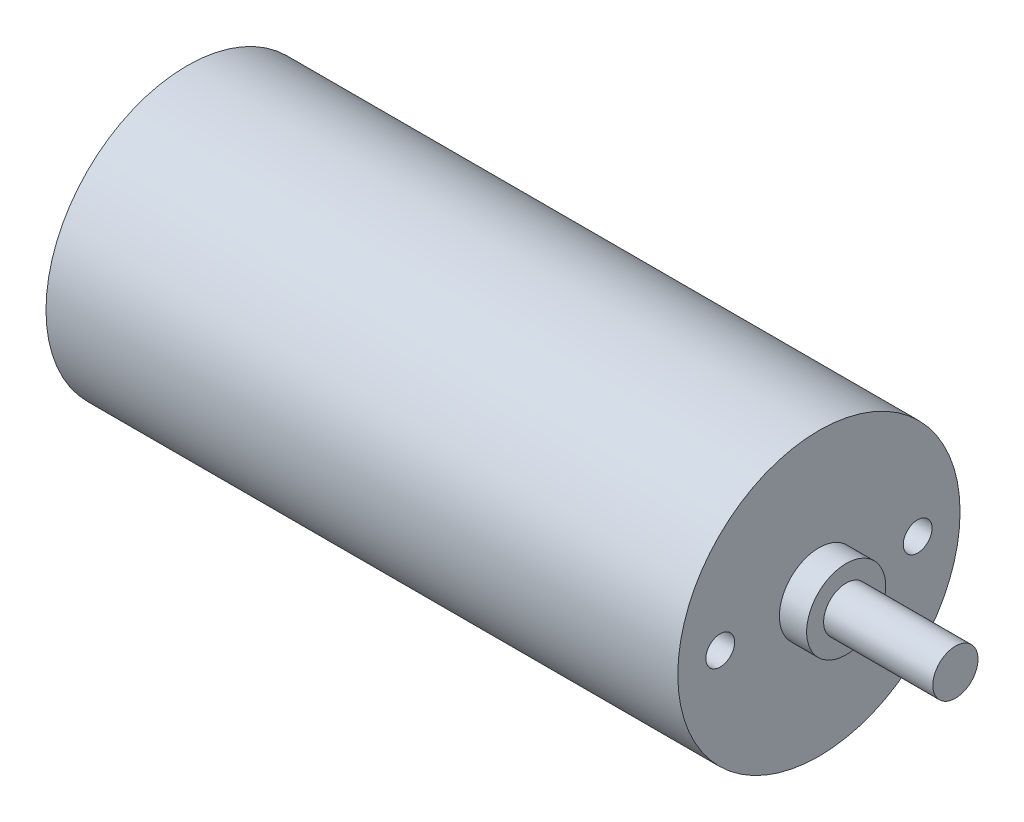
from build123d import *

# Parameters (mm, degrees)
SKETCH1_R           = 1.99
BOSS_EXTRUDE1_DEPTH = 12.03
SKETCH1_3_R         = 3.485
SKETCH1_3_R_2       = 1.99
BOSS_EXTRUDE2_DEPTH = 2.4
SKETCH1_4_R         = 12.44
SKETCH1_4_R_2       = 1.27
SKETCH1_4_R_3       = 3.485
BOSS_EXTRUDE3_DEPTH = 55.69


with BuildPart() as part:
    # Sketch1 → Boss-Extrude1 (new body)
    with BuildSketch(Plane(origin=(0, 0, 0), x_dir=(0, 0, -1), z_dir=(1, 0, 0))):
        Circle(SKETCH1_R)
    extrude(amount=BOSS_EXTRUDE1_DEPTH)

    # Sketch1_3 → Boss-Extrude2 (add)
    with BuildSketch(Plane(origin=(0, 0, 0), x_dir=(0, 0, -1), z_dir=(1, 0, 0))):
        Circle(SKETCH1_3_R)
        Circle(SKETCH1_3_R_2, mode=Mode.SUBTRACT)
    extrude(amount=BOSS_EXTRUDE2_DEPTH)


with BuildPart() as body_2:
    # Sketch1_4 → Boss-Extrude3 (new body)
    with BuildSketch(Plane(origin=(0, 0, 0), x_dir=(0, 0, -1), z_dir=(1, 0, 0))):
        Circle(SKETCH1_4_R)
        with Locations((-8.7, 0)):
            Circle(SKETCH1_4_R_2, mode=Mode.SUBTRACT)
        Circle(SKETCH1_4_R_3, mode=Mode.SUBTRACT)
        with Locations((8.7, 0)):
            Circle(SKETCH1_4_R_2, mode=Mode.SUBTRACT)
    extrude(amount=-BOSS_EXTRUDE3_DEPTH)


solid = Compound([part.part, body_2.part])
